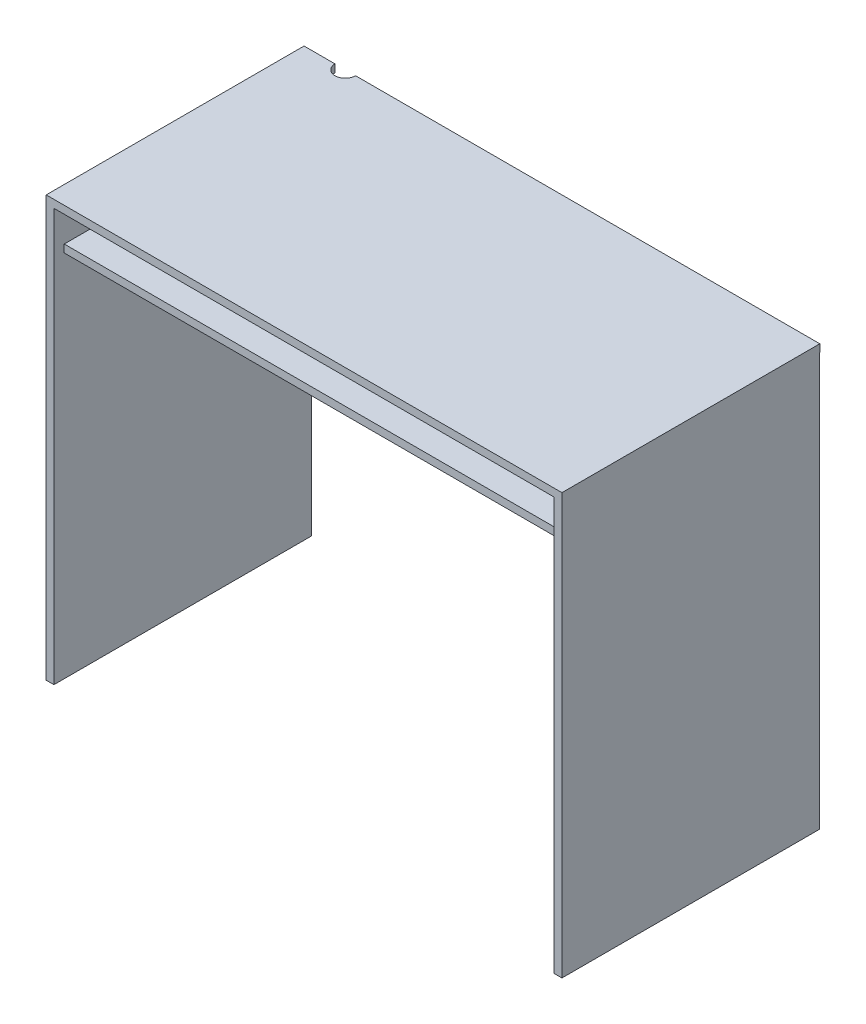
from build123d import *

# Parameters (mm, degrees)
SKETCH1_W           = 1000
SKETCH1_H           = 500
BOSS_EXTRUDE1_DEPTH = 15
SKETCH2_W           = 15
SKETCH2_H           = 499.509580663
BOSS_EXTRUDE2_DEPTH = 800
BOSS_EXTRUDE3_REACH = 987
SKETCH3_W           = 459.509580663
SKETCH3_H           = 15
SKETCH4_R           = 20
CUT_EXTRUDE1_DEPTH  = 816


with BuildPart() as part:
    # Sketch1 → Boss-Extrude1 (new body)
    with BuildSketch(Plane(origin=(0, 0, 0), x_dir=(1, 0, 0), z_dir=(0, 1, 0))):
        Rectangle(SKETCH1_W, SKETCH1_H)
    extrude(amount=BOSS_EXTRUDE1_DEPTH)

    # Sketch2 → Boss-Extrude2 (add)
    with BuildSketch(Plane.XZ):
        with Locations((-492.5, 0.245209669)):
            Rectangle(SKETCH2_W, SKETCH2_H)
        with Locations((492.5, 0.245209669)):
            Rectangle(SKETCH2_W, SKETCH2_H)
    extrude(amount=BOSS_EXTRUDE2_DEPTH)

    # Sketch3 → Boss-Extrude3 (add, up to next)
    with BuildSketch(Plane(origin=(-485, 0, 0), x_dir=(0, 0, -1), z_dir=(1, 0, 0)), mode=Mode.PRIVATE) as boss_extrude3_sk1:
        with Locations((-0.245209669, -77.5)):
            Rectangle(SKETCH3_W, SKETCH3_H)
    boss_extrude3_tool1 = extrude(boss_extrude3_sk1.sketch, amount=BOSS_EXTRUDE3_REACH, mode=Mode.PRIVATE) - part.part
    add(boss_extrude3_tool1.solids().sort_by_distance((-485, -77.5, 0.24521))[0])

    # Sketch4 → Cut-Extrude1 (cut, through all)
    with BuildSketch(Plane(origin=(0, 15, 0), x_dir=(1, 0, 0), z_dir=(0, 1, 0))):
        with Locations((-420, 250)):
            Circle(SKETCH4_R)
    extrude(amount=-CUT_EXTRUDE1_DEPTH, mode=Mode.SUBTRACT)


solid = part.part
